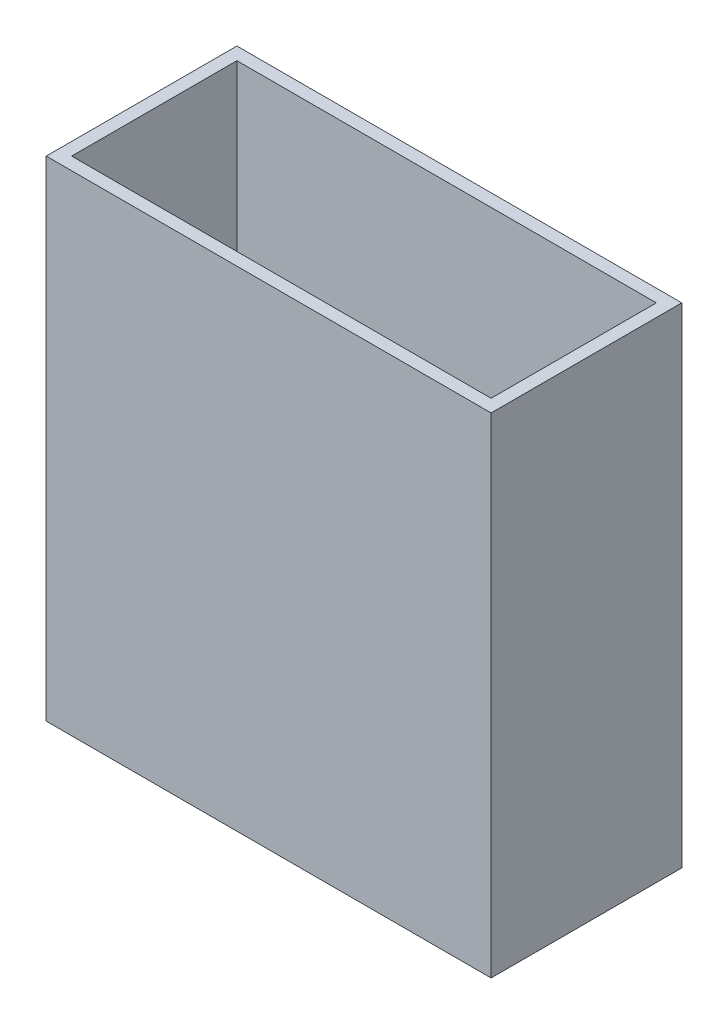
from build123d import *

# Parameters (mm, degrees)
SKETCH1_W           = 140
SKETCH1_H           = 60
SKETCH1_W_2         = 132
SKETCH1_H_2         = 52
BOSS_EXTRUDE1_DEPTH = 150
BOSS_EXTRUDE3_DEPTH = 60
CUT_EXTRUDE1_DEPTH  = 4
SKETCH5_W           = 2.5
SKETCH5_H           = 4.1
CUT_EXTRUDE2_DEPTH  = 4


with BuildPart() as part:
    # Sketch1 → Boss-Extrude1 (new body)
    with BuildSketch(Plane(origin=(0, 0, 0), x_dir=(1, 0, 0), z_dir=(0, 1, 0))):
        with Locations((70, -30)):
            Rectangle(SKETCH1_W, SKETCH1_H)
        with Locations((70, -30)):
            Rectangle(SKETCH1_W_2, SKETCH1_H_2, mode=Mode.SUBTRACT)
    extrude(amount=BOSS_EXTRUDE1_DEPTH)

    # Sketch3 → Boss-Extrude3 (add)
    with BuildSketch(Plane.XY):
        Polygon((0, 0), (140, 6), (140, -4), (0, -4), align=None)
    extrude(amount=BOSS_EXTRUDE3_DEPTH)

    # Sketch4 → Cut-Extrude1 (cut)
    with BuildSketch(Plane.ZY):
        with BuildLine():
            Line((27, 0), (33, 0))
            Line((33, 0), (33, 2))
            add(Edge.make_bspline(
                [(33, 2), (33, 4.5), (30, 4.5), (27, 4.5), (27, 2)],
                knots=[3.141592654, 3.141592654, 3.141592654, 4.71238898, 4.71238898, 6.283185307, 6.283185307, 6.283185307], degree=2, weights=[1, 0.707106781, 1, 0.707106781, 1]))
            Line((27, 2), (27, 0))
        make_face()
    extrude(amount=-CUT_EXTRUDE1_DEPTH, mode=Mode.SUBTRACT)

    # Sketch5 → Cut-Extrude2 (cut)
    with BuildSketch(Plane.ZY):
        with Locations((39.75, 7)):
            Rectangle(SKETCH5_W, SKETCH5_H)
        with Locations((20.25, 7)):
            Rectangle(SKETCH5_W, SKETCH5_H)
    extrude(amount=-CUT_EXTRUDE2_DEPTH, mode=Mode.SUBTRACT)


solid = part.part
